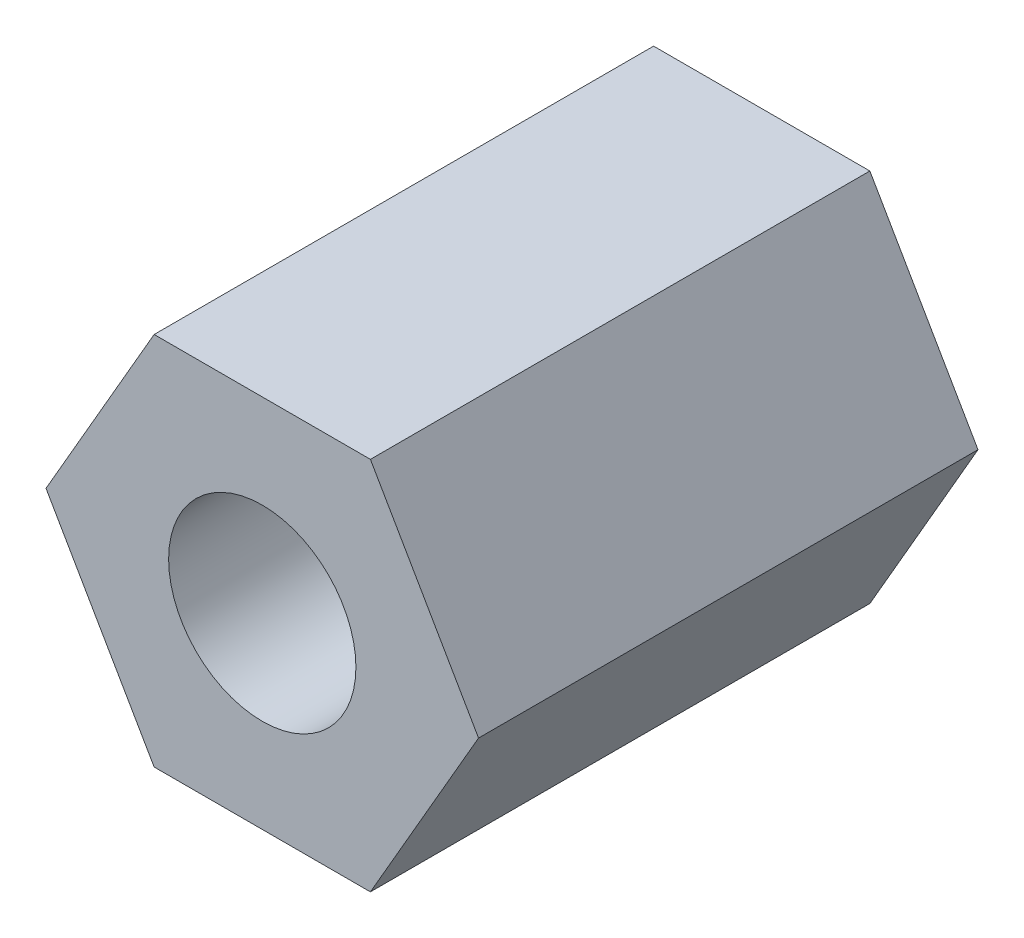
from build123d import *

# Parameters (mm, degrees)
SKETCH_1_R      = 1.5
EXTRUDE_1_DEPTH = 8


with BuildPart() as part:
    # 草图1 → 凸台-拉伸1 (new body)
    with BuildSketch(Plane.XY):
        Polygon((1.732050808, 3), (-1.732050808, 3), (-3.464101615, 0), (-1.732050808, -3), (1.732050808, -3), (3.464101615, 0), align=None)
        Circle(SKETCH_1_R, mode=Mode.SUBTRACT)
    extrude(amount=EXTRUDE_1_DEPTH)


solid = part.part
